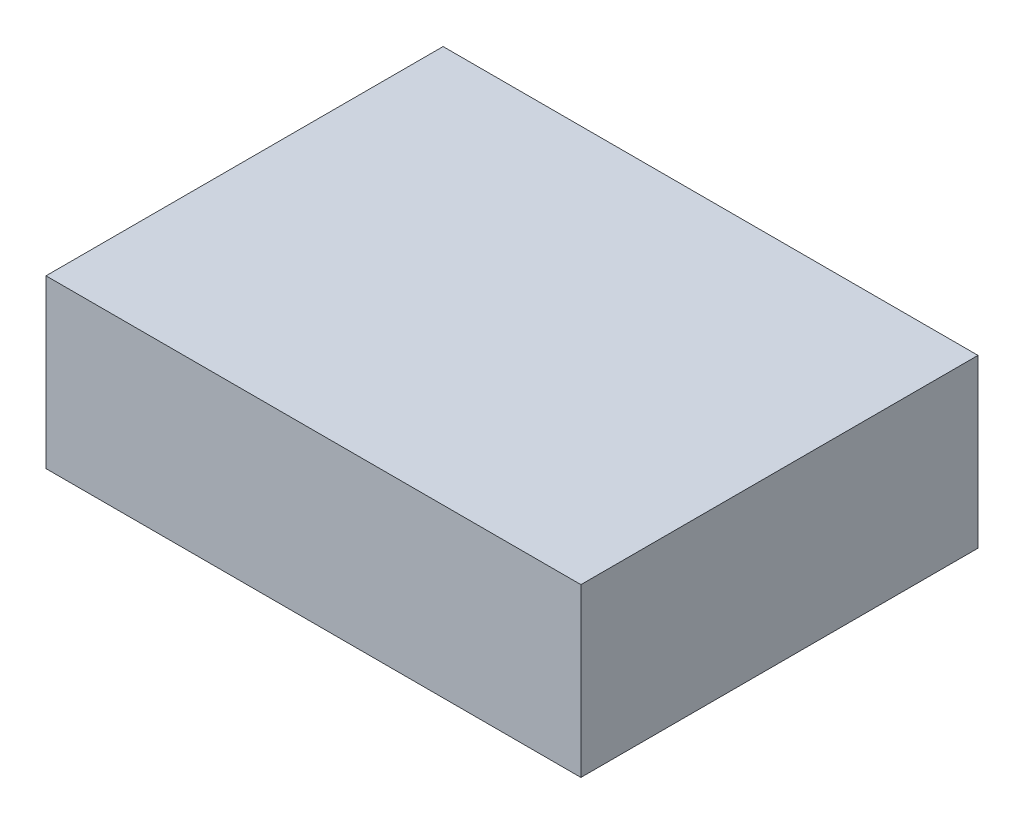
from build123d import *

# Parameters (mm, degrees)
CROQUIS1_W              = 480.447113354
CROQUIS1_H              = 356.667346828
SALIENTE_EXTRUIR1_DEPTH = 150


with BuildPart() as part:
    # Croquis1 → Saliente-Extruir1 (new body)
    with BuildSketch(Plane(origin=(0, 0, 0), x_dir=(1, 0, 0), z_dir=(0, 1, 0))):
        Rectangle(CROQUIS1_W, CROQUIS1_H)
    extrude(amount=SALIENTE_EXTRUIR1_DEPTH)


solid = part.part
